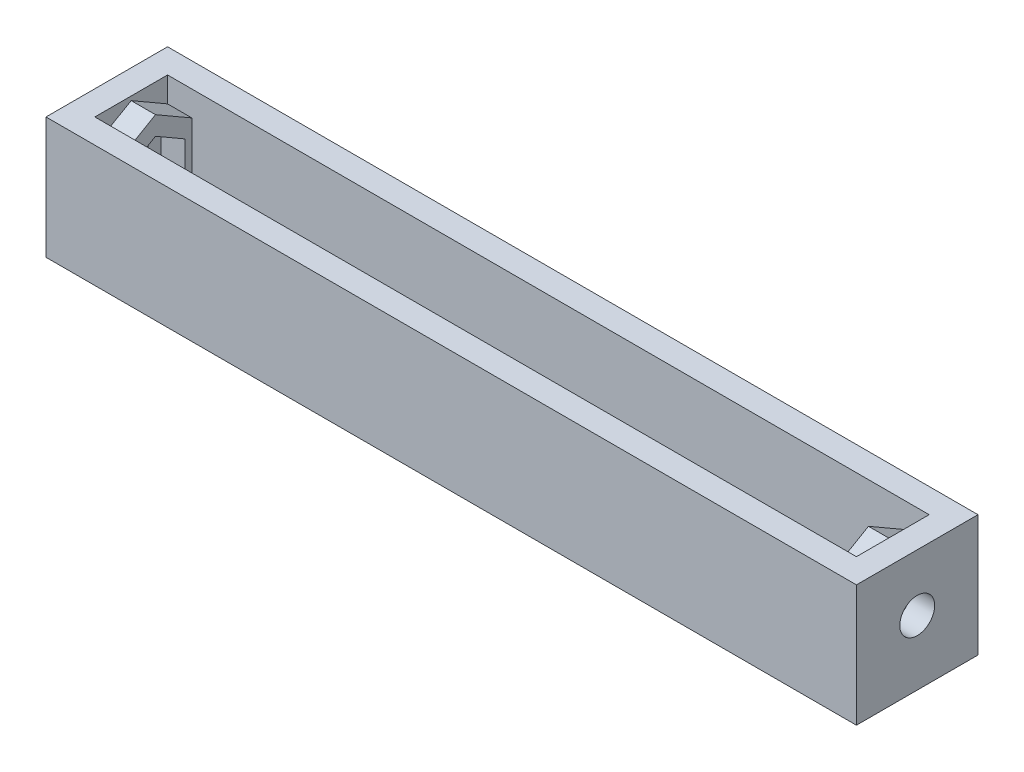
from build123d import *

# Parameters (mm, degrees)
SKETCH_1_W          = 100
SKETCH_1_H          = 15
EXTRUDE_1_DEPTH     = 15
SHELL_1_T           = -3.01271481
EXTRUDE_2_DEPTH     = 3
SKETCH_4_R          = 2.15
CUT_EXTRUDE_1_DEPTH = 4.01271481
EXTRUDE_3_DEPTH     = 3
SKETCH_6_R          = 2.15
CUT_EXTRUDE_2_DEPTH = 4.01271481


with BuildPart() as part:
    # 草图1 → 凸台-拉伸1 (new body)
    with BuildSketch(Plane(origin=(0, 0, 0), x_dir=(1, 0, 0), z_dir=(0, 1, 0))):
        with Locations((50, 7.5)):
            Rectangle(SKETCH_1_W, SKETCH_1_H)
    extrude(amount=EXTRUDE_1_DEPTH)

    # 抽壳1
    shell_1_openings = [part.faces().sort_by_distance(p)[0] for p in [
        (50, 15, -7.5),
    ]]
    offset(amount=SHELL_1_T, openings=shell_1_openings, kind=Kind.INTERSECTION)

    # 草图3 → 凸台-拉伸2 (add)
    with BuildSketch(Plane(origin=(3.01271481, 0, 0), x_dir=(0, 0, -1), z_dir=(1, 0, 0))):
        Polygon((1.85, 4.713912937), (7.5, 1.451883916), (13.15, 4.713912937), (13.15, 11.237970979), (7.5, 14.5), (1.85, 11.237970979), align=None)
        Polygon((7.5, 3.761284993), (11.15, 5.868613476), (11.15, 10.083270441), (7.5, 12.190598923), (3.85, 10.083270441), (3.85, 5.868613476), align=None, mode=Mode.SUBTRACT)
    extrude(amount=EXTRUDE_2_DEPTH)

    # 草图4 → 切除-拉伸1 (cut, through all)
    with BuildSketch(Plane(origin=(3.01271481, 0, 0), x_dir=(0, 0, -1), z_dir=(1, 0, 0))):
        with Locations((7.5, 7.975941958)):
            Circle(SKETCH_4_R)
    extrude(amount=-CUT_EXTRUDE_1_DEPTH, mode=Mode.SUBTRACT)

    # 草图5 → 凸台-拉伸3 (add)
    with BuildSketch(Plane.ZY.offset(-96.98728519)):
        Polygon((-3.01271481, 11.909264688), (-7.5, 14.5), (-11.98728519, 11.909264688), (-11.98728519, 4.042619229), (-10.20343841, 3.01271481), (-4.79656159, 3.01271481), (-3.01271481, 4.042619229), align=None)
        Polygon((-11.15, 10.083270441), (-7.5, 12.190598923), (-3.85, 10.083270441), (-3.85, 5.868613476), (-7.5, 3.761284993), (-11.15, 5.868613476), align=None, mode=Mode.SUBTRACT)
    extrude(amount=EXTRUDE_3_DEPTH)

    # 草图6 → 切除-拉伸2 (cut, through all)
    with BuildSketch(Plane.ZY.offset(-96.98728519)):
        with Locations((-7.5, 7.975941958)):
            Circle(SKETCH_6_R)
    extrude(amount=-CUT_EXTRUDE_2_DEPTH, mode=Mode.SUBTRACT)


solid = part.part
